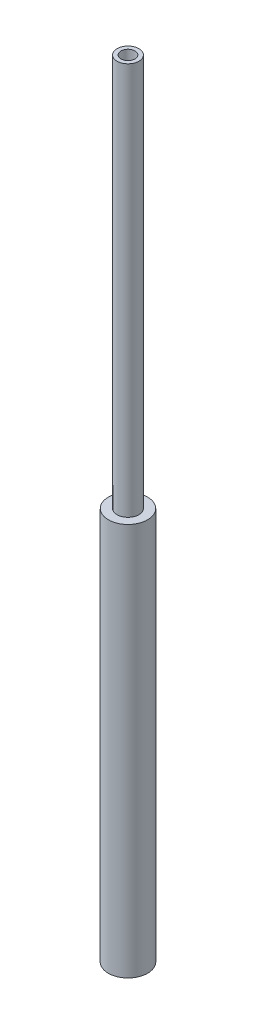
from build123d import *

# Parameters (mm, degrees)
SKETCH1_R           = 1.389
SKETCH1_R_2         = 0.889
BOSS_EXTRUDE1_DEPTH = 100
SKETCH2_R           = 2.5
BOSS_EXTRUDE2_DEPTH = 50


with BuildPart() as part:
    # Sketch1 → Boss-Extrude1 (new body)
    with BuildSketch(Plane(origin=(0, 0, 0), x_dir=(1, 0, 0), z_dir=(0, 1, 0))):
        Circle(SKETCH1_R)
        Circle(SKETCH1_R_2, mode=Mode.SUBTRACT)
    extrude(amount=BOSS_EXTRUDE1_DEPTH)

    # Sketch2 → Boss-Extrude2 (add)
    with BuildSketch(Plane(origin=(0, 0, 0), x_dir=(1, 0, 0), z_dir=(0, 1, 0))):
        Circle(SKETCH2_R)
    extrude(amount=BOSS_EXTRUDE2_DEPTH)


solid = part.part
